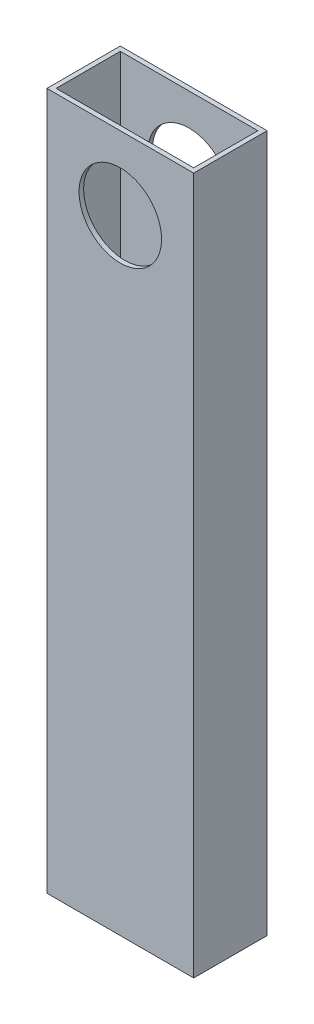
from build123d import *

# Parameters (mm, degrees)
SKETCH1_W           = 50.8
SKETCH1_H           = 25.4
SKETCH1_W_2         = 47.625
SKETCH1_H_2         = 22.225
BOSS_EXTRUDE1_DEPTH = 241.3
SKETCH2_R           = 14.288114564
CUT_EXTRUDE1_DEPTH  = 26.4


with BuildPart() as part:
    # Sketch1 → Boss-Extrude1 (new body)
    with BuildSketch(Plane(origin=(0, 0, 0), x_dir=(1, 0, 0), z_dir=(0, 1, 0))):
        with Locations((10.16, -7.65175)):
            Rectangle(SKETCH1_W, SKETCH1_H)
        with Locations((10.16, -7.65175)):
            Rectangle(SKETCH1_W_2, SKETCH1_H_2, mode=Mode.SUBTRACT)
    extrude(amount=BOSS_EXTRUDE1_DEPTH)

    # Sketch2 → Cut-Extrude1 (cut, through all)
    with BuildSketch(Plane(origin=(0, 0, -5.04825), x_dir=(-1, 0, 0), z_dir=(0, 0, -1))):
        with Locations((-10.16, 215.9)):
            Circle(SKETCH2_R)
    extrude(amount=-CUT_EXTRUDE1_DEPTH, mode=Mode.SUBTRACT)


solid = part.part
